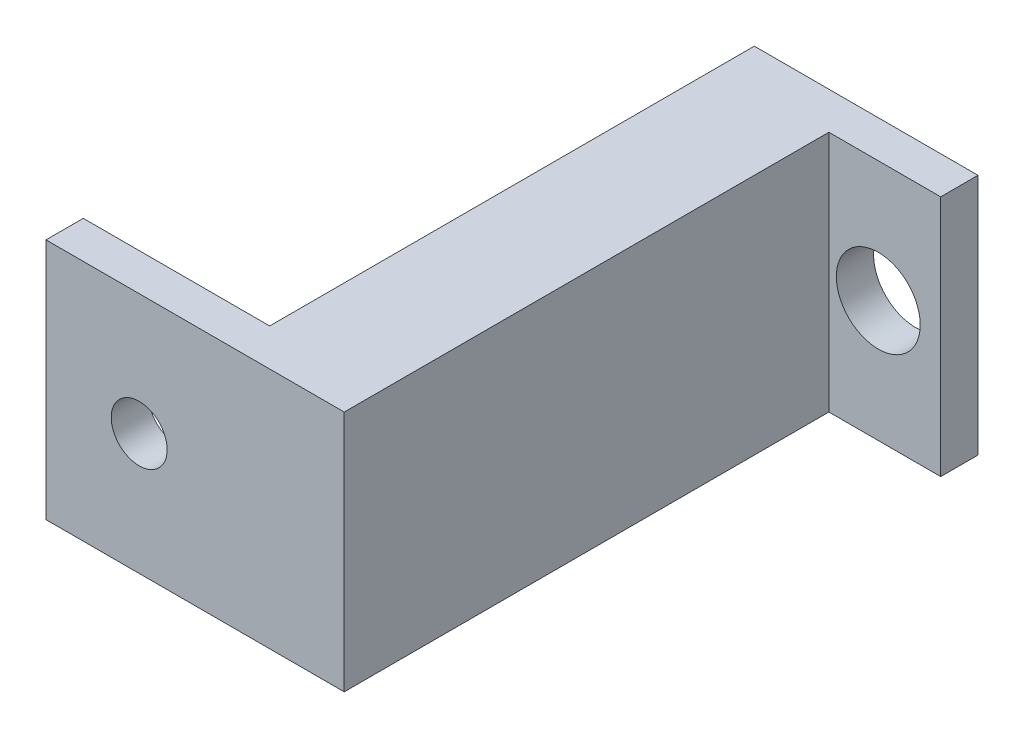
from build123d import *

# Parameters (mm, degrees)
SZKIC1_W                    = 12
SZKIC1_H                    = 13
SZKIC1_R                    = 2.25
DODANIE_WYCI_GNI_CIE1_DEPTH = 2
SZKIC2_W                    = 6
SZKIC2_H                    = 13
DODANIE_WYCI_GNI_CIE2_DEPTH = 24
SZKIC3_W                    = 16
SZKIC3_H                    = 13
SZKIC3_R                    = 1.5
DODANIE_WYCI_GNI_CIE3_DEPTH = 2


with BuildPart() as part:
    # Szkic1 → Dodanie-wyciągnięcie1 (new body)
    with BuildSketch(Plane.XY):
        Rectangle(SZKIC1_W, SZKIC1_H)
        with Locations((2.65, 0)):
            Circle(SZKIC1_R, mode=Mode.SUBTRACT)
    extrude(amount=DODANIE_WYCI_GNI_CIE1_DEPTH)

    # Szkic2 → Dodanie-wyciągnięcie2 (add)
    with BuildSketch(Plane.XY.offset(2)):
        with Locations((-3, 0)):
            Rectangle(SZKIC2_W, SZKIC2_H)
    extrude(amount=DODANIE_WYCI_GNI_CIE2_DEPTH)

    # Szkic3 → Dodanie-wyciągnięcie3 (add)
    with BuildSketch(Plane.XY.offset(26)):
        with Locations((-8, 0)):
            Rectangle(SZKIC3_W, SZKIC3_H)
        with Locations((-11, 0)):
            Circle(SZKIC3_R, mode=Mode.SUBTRACT)
    extrude(amount=DODANIE_WYCI_GNI_CIE3_DEPTH)


solid = part.part
